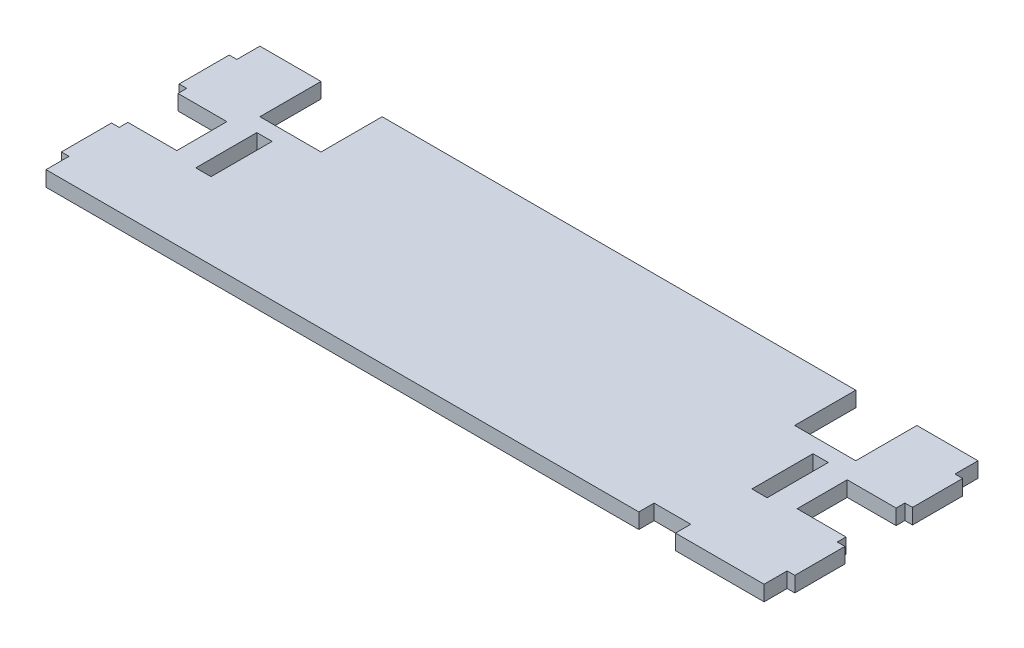
from build123d import *

# Parameters (mm, degrees)
BOSS_EXTRUDE1_DEPTH     = 3.175
SKETCH2_W               = 6.35
SKETCH2_H               = 25.4
CUT_EXTRUDE1_DEPTH      = 4.175
CUT_EXTRUDE1_DEPTH_BACK = 4.175


with BuildPart() as part:
    # Sketch1 → Boss-Extrude1 (new body, symmetric)
    with BuildSketch(Plane(origin=(0, 0, 0), x_dir=(1, 0, 0), z_dir=(0, 1, 0))):
        Polygon((149.225, -44.45), (112.395, -44.45), (112.395, -38.1), (97.155, -38.1), (97.155, -44.45), (-149.225, -44.45), (-149.225, -34.874677354), (-152.4, -34.874677354), (-152.4, -14.046677354), (-149.225, -14.046677354), (-149.225, -10.414), (-128.905, -10.414), (-128.905, 10.414), (-149.225, 10.414), (-149.225, 14.046677354), (-152.4, 14.046677354), (-152.4, 34.874677354), (-149.225, 34.874677354), (-149.225, 44.45), (-123.825, 44.45), (-123.825, 19.05), (-98.425, 19.05), (-98.425, 44.45), (98.425, 44.45), (98.425, 19.05), (123.825, 19.05), (123.825, 44.45), (149.225, 44.45), (149.225, 34.874677354), (152.4, 34.874677354), (152.4, 14.046677354), (149.225, 14.046677354), (149.225, 10.414), (128.905, 10.414), (128.905, -10.414), (149.225, -10.414), (149.225, -14.046677354), (152.4, -14.046677354), (152.4, -34.874677354), (149.225, -34.874677354), align=None)
    extrude(amount=BOSS_EXTRUDE1_DEPTH, both=True)

    # Sketch2 → Cut-Extrude1 (cut, two sides)
    with BuildSketch(Plane(origin=(0, 0, 0), x_dir=(1, 0, 0), z_dir=(0, 1, 0))) as cut_extrude1_sk:
        with Locations((115.57, 0)):
            Rectangle(SKETCH2_W, SKETCH2_H)
        with Locations((-115.57, 0)):
            Rectangle(SKETCH2_W, SKETCH2_H)
    extrude(amount=CUT_EXTRUDE1_DEPTH, mode=Mode.SUBTRACT)
    extrude(cut_extrude1_sk.sketch, amount=-CUT_EXTRUDE1_DEPTH_BACK, mode=Mode.SUBTRACT)


solid = part.part
